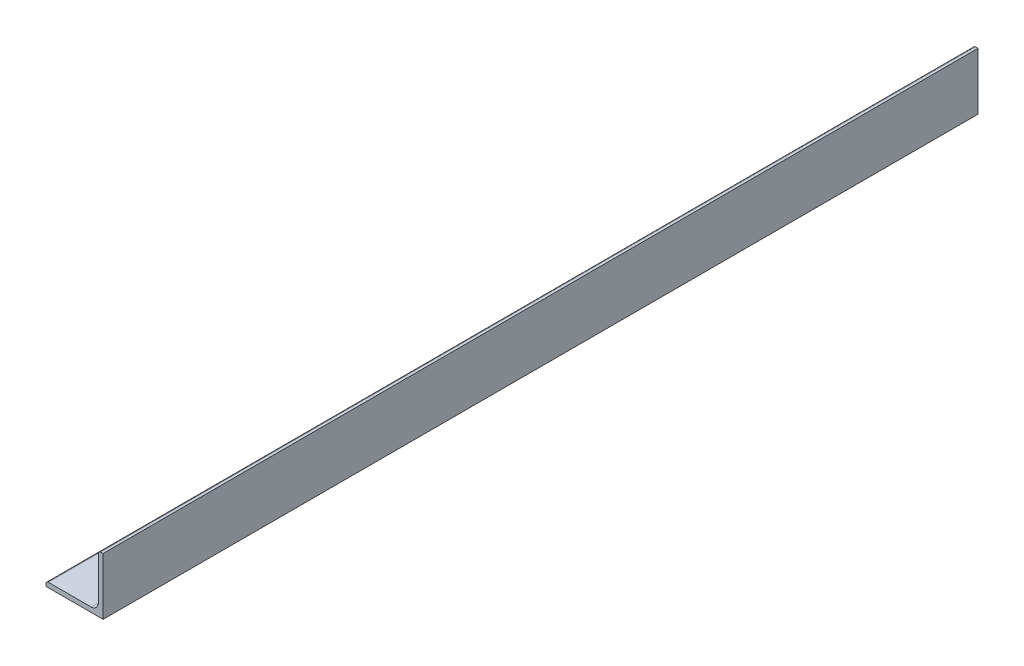
from build123d import *

# Parameters (mm, degrees)
BOSS_EXTRUDE1_DEPTH = 609.6
SKETCH3_W           = 635.2
SKETCH3_H           = 38.1
CUT_EXTRUDE1_DEPTH  = 60


with BuildPart() as part:
    # Sketch2 → Boss-Extrude1 (new, symmetric)
    with BuildSketch(Plane.XY):
        with BuildLine():
            Line((-19.05, -19.05), (19.05, -19.05))
            Line((19.05, -19.05), (19.05, 19.05))
            Line((19.05, 19.05), (17.4625, 19.05))
            ThreePointArc((17.4625, 19.05), (16.339967985, 18.585032015), (15.875, 17.4625))
            Line((15.875, 17.4625), (15.875, -11.0998))
            ThreePointArc((15.875, -11.0998), (14.476376302, -14.476376302), (11.0998, -15.875))
            Line((11.0998, -15.875), (-17.4625, -15.875))
            ThreePointArc((-17.4625, -15.875), (-18.585032015, -16.339967985), (-19.05, -17.4625))
            Line((-19.05, -17.4625), (-19.05, -19.05))
        make_face()
    extrude(amount=BOSS_EXTRUDE1_DEPTH, both=True)

    # Sketch3 → Cut-Extrude1 (cut)
    with BuildSketch(Plane(origin=(19.05, 0, 0), x_dir=(0, 0, -1), z_dir=(1, 0, 0))):
        with Locations((292, 0)):
            Rectangle(SKETCH3_W, SKETCH3_H)
    extrude(amount=-CUT_EXTRUDE1_DEPTH, mode=Mode.SUBTRACT)


solid = part.part
